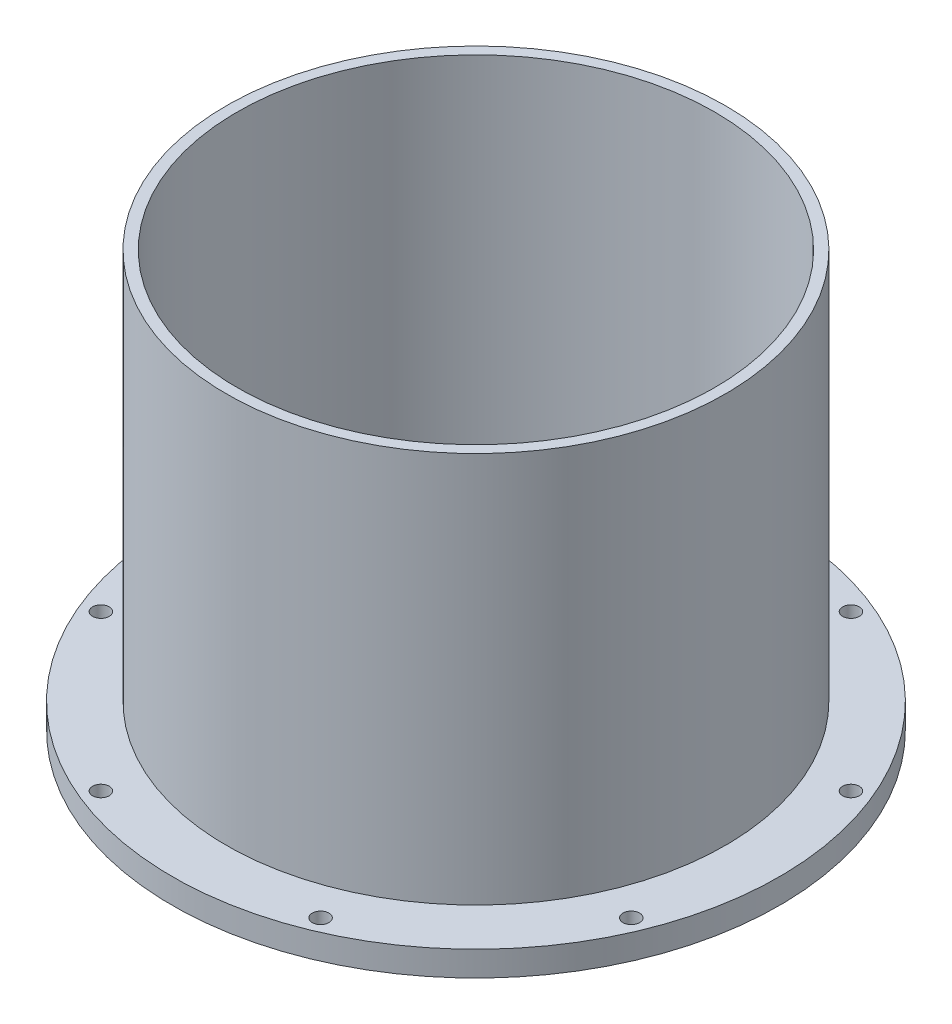
from build123d import *

# Parameters (mm, degrees)
SKETCH_3_R               = 5
CUT_EXTRUDE_1_DEPTH      = 15
PATTERN_CIRCULAR_1_COUNT = 8


with BuildPart() as part:
    # 스케치2 → 회전1 (revolve)
    with BuildSketch(Plane.XY, mode=Mode.PRIVATE) as revolve_1_sk:
        Polygon((-182.5, 0), (-182.5, 15), (-150, 15), (-150, 250), (-143.5, 250), (-143.5, 0), align=None)
    revolve(revolve_1_sk.sketch.rotate(Axis((0, 0, 0), (0, 1, 0)), 270), axis=Axis((0, 0, 0), (0, 1, 0)))  # turned: the seam where the file's is

    # 스케치3 → 컷-돌출1 (cut)
    with BuildSketch(Plane(origin=(0, 0, 0), x_dir=(1, 0, 0), z_dir=(0, 1, 0))):
        with Locations(Location((159.369219358, 66.012892083, 0), (0, 0, 90))):  # turned: the seam where the file's is
            Circle(SKETCH_3_R)
    cut_extrude_1 = extrude(amount=CUT_EXTRUDE_1_DEPTH, mode=Mode.SUBTRACT)

    # 원형 패턴1: 컷-돌출1 ×8 about axis
    pattern_circular_1_axis = Axis((0, 0, 0), (0, 1, 0))
    for i in range(1, PATTERN_CIRCULAR_1_COUNT):
        add(cut_extrude_1.rotate(pattern_circular_1_axis, i * 360 / PATTERN_CIRCULAR_1_COUNT), mode=Mode.SUBTRACT)


solid = part.part
